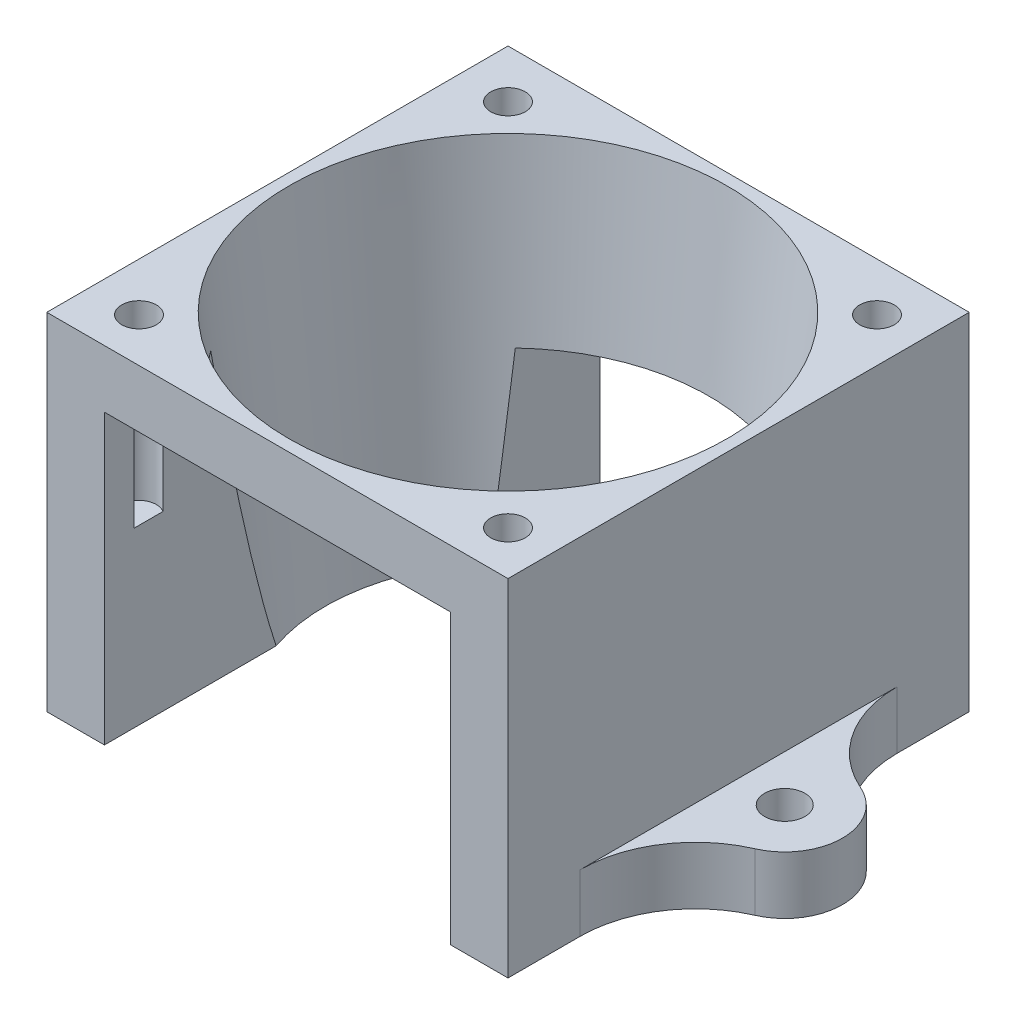
from build123d import *

# Parameters (mm, degrees)
SKETCH1_W           = 40
SKETCH1_H           = 40
BOSS_EXTRUDE1_DEPTH = 30
SKETCH2_R           = 19
CUT_EXTRUDE1_DEPTH  = 30
CUT_EXTRUDE1_TAPER  = 6
SKETCH3_R           = 1.5
CUT_EXTRUDE2_DEPTH  = 15
SKETCH4_W           = 24
SKETCH4_H           = 15
CUT_EXTRUDE3_DEPTH  = 41
SKETCH5_W           = 30
SKETCH5_H           = 25
CUT_EXTRUDE4_DEPTH  = 15
SKETCH7_R           = 1.75
BOSS_EXTRUDE2_DEPTH = 5
FILLET1_R           = 10
FILLET2_R           = 10


with BuildPart() as part:
    # Sketch1 → Boss-Extrude1 (new body)
    with BuildSketch(Plane(origin=(0, 0, 0), x_dir=(1, 0, 0), z_dir=(0, 1, 0))):
        Rectangle(SKETCH1_W, SKETCH1_H)
    extrude(amount=BOSS_EXTRUDE1_DEPTH)

    # Sketch2 → Cut-Extrude1 (cut)
    with BuildSketch(Plane(origin=(0, 30, 0), x_dir=(1, 0, 0), z_dir=(0, 1, 0))):
        Circle(SKETCH2_R)
    extrude(amount=-CUT_EXTRUDE1_DEPTH, taper=CUT_EXTRUDE1_TAPER, mode=Mode.SUBTRACT)

    # Sketch3 → Cut-Extrude2 (cut)
    with BuildSketch(Plane(origin=(0, 30, 0), x_dir=(1, 0, 0), z_dir=(0, 1, 0))):
        with Locations((-15.810907627, 15.810907627)):
            Circle(SKETCH3_R)
        with Locations((16.189092373, 15.810907627)):
            Circle(SKETCH3_R)
        with Locations((16.189092373, -16.189092373)):
            Circle(SKETCH3_R)
        with Locations((-15.810907627, -16.189092373)):
            Circle(SKETCH3_R)
    extrude(amount=-CUT_EXTRUDE2_DEPTH, mode=Mode.SUBTRACT)

    # Sketch4 → Cut-Extrude3 (cut, through all)
    with BuildSketch(Plane(origin=(0, 0, -20), x_dir=(-1, 0, 0), z_dir=(0, 0, -1))):
        with Locations((0, 7.5)):
            Rectangle(SKETCH4_W, SKETCH4_H)
    extrude(amount=-CUT_EXTRUDE3_DEPTH, mode=Mode.SUBTRACT)

    # Sketch5 → Cut-Extrude4 (cut)
    with BuildSketch(Plane.XY.offset(20)):
        with Locations((0, 12.5)):
            Rectangle(SKETCH5_W, SKETCH5_H)
    extrude(amount=-CUT_EXTRUDE4_DEPTH, mode=Mode.SUBTRACT)

    # Sketch7 → Boss-Extrude2 (add)
    with BuildSketch(Plane.XZ):
        with BuildLine():
            Line((-20, 3), (-20, -3))
            ThreePointArc((-20, -3), (-29, 0), (-20, 3))
        make_face()
        with Locations((-24, 0)):
            Circle(SKETCH7_R, mode=Mode.SUBTRACT)
        with BuildLine():
            Line((20, 3), (20, -3))
            ThreePointArc((20, -3), (29, 0), (20, 3))
        make_face()
        with Locations((24, 0)):
            Circle(SKETCH7_R, mode=Mode.SUBTRACT)
    extrude(amount=-BOSS_EXTRUDE2_DEPTH)

    # Fillet1
    fillet1_edges = [part.edges().sort_by_distance(p)[0] for p in [
        (-20, 2.5, 3),
    ]]
    fillet(fillet1_edges, radius=FILLET1_R)

    # Fillet2
    fillet2_edges = [part.edges().sort_by_distance(p)[0] for p in [
        (-20, 2.5, -3),
        (20, 2.5, 3),
        (20, 2.5, -3),
    ]]
    fillet(fillet2_edges, radius=FILLET2_R)


solid = part.part
